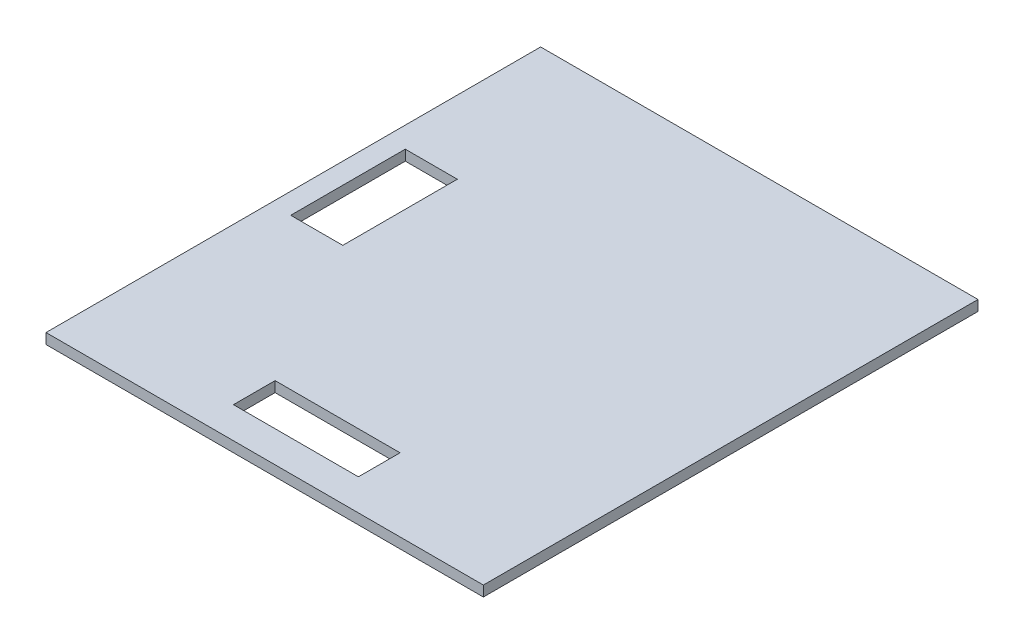
from build123d import *

# Parameters (mm, degrees)
SKETCH1_W           = 42
SKETCH1_H           = 47.5
BOSS_EXTRUDE1_DEPTH = 1
SKETCH2_W           = 5
SKETCH2_H           = 11
SKETCH2_W_2         = 12
SKETCH2_H_2         = 4
CUT_EXTRUDE1_DEPTH  = 5


with BuildPart() as part:
    # Sketch1 → Boss-Extrude1 (new body)
    with BuildSketch(Plane(origin=(0, 0, 0), x_dir=(1, 0, 0), z_dir=(0, 1, 0))):
        Rectangle(SKETCH1_W, SKETCH1_H)
    extrude(amount=BOSS_EXTRUDE1_DEPTH)

    # Sketch2 → Cut-Extrude1 (cut)
    with BuildSketch(Plane(origin=(0, 0, 0), x_dir=(1, 0, 0), z_dir=(0, 1, 0))):
        with Locations((-16.5, 3.25)):
            Rectangle(SKETCH2_W, SKETCH2_H)
        with Locations((0, -18.75)):
            Rectangle(SKETCH2_W_2, SKETCH2_H_2)
    extrude(amount=CUT_EXTRUDE1_DEPTH, mode=Mode.SUBTRACT)


solid = part.part
